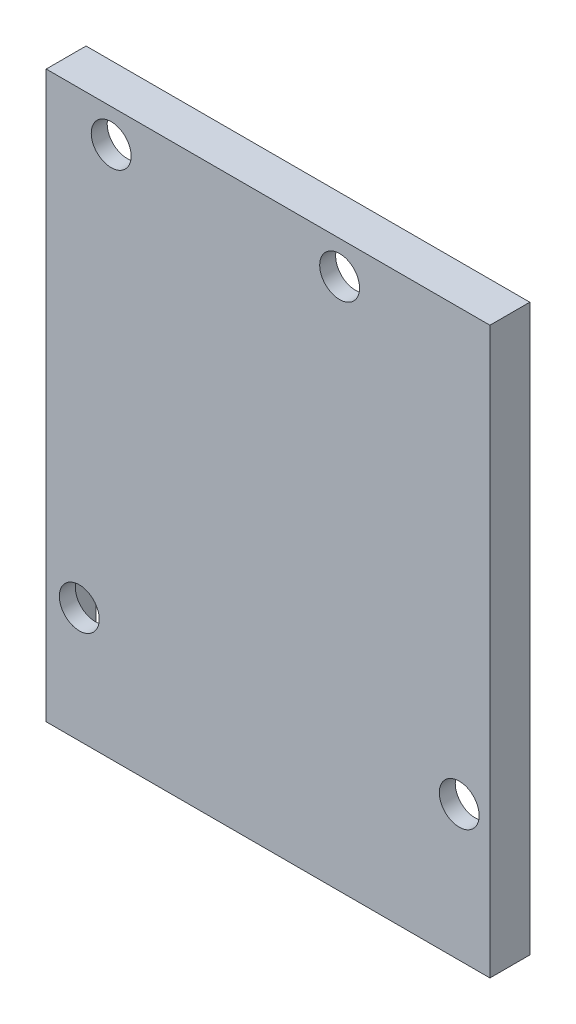
from build123d import *

# Parameters (mm, degrees)
SKETCH1_W           = 55.65
SKETCH1_H           = 70.9
BOSS_EXTRUDE1_DEPTH = 5
SKETCH3_W           = 53.15
SKETCH3_H           = 68.4
CUT_EXTRUDE1_DEPTH  = 3
SKETCH2_R           = 2.5
CUT_EXTRUDE2_DEPTH  = 6


with BuildPart() as part:
    # Sketch1 → Boss-Extrude1 (new body)
    with BuildSketch(Plane.XY):
        Rectangle(SKETCH1_W, SKETCH1_H)
    extrude(amount=BOSS_EXTRUDE1_DEPTH)

    # Sketch3 → Cut-Extrude1 (cut)
    with BuildSketch(Plane(origin=(0, 0, 0), x_dir=(-1, 0, 0), z_dir=(0, 0, -1))):
        Rectangle(SKETCH3_W, SKETCH3_H)
    extrude(amount=-CUT_EXTRUDE1_DEPTH, mode=Mode.SUBTRACT)

    # Sketch2 → Cut-Extrude2 (cut, through all)
    with BuildSketch(Plane(origin=(0, 0, 0), x_dir=(-1, 0, 0), z_dir=(0, 0, -1))):
        with Locations((-8.973470341, 31.308167243)):
            Circle(SKETCH2_R)
        with Locations((-23.973470341, -18.491832757)):
            Circle(SKETCH2_R)
        with Locations((23.676529659, -20.991832757)):
            Circle(SKETCH2_R)
        with Locations((19.676529659, 31.308167243)):
            Circle(SKETCH2_R)
    extrude(amount=-CUT_EXTRUDE2_DEPTH, mode=Mode.SUBTRACT)


solid = part.part
